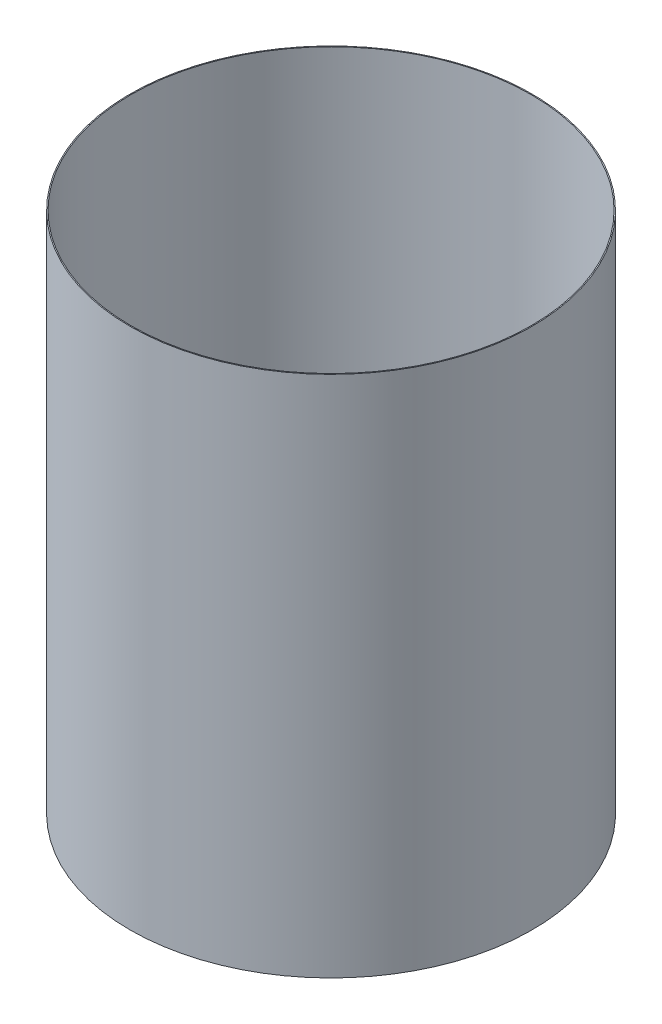
from build123d import *

# Parameters (mm, degrees)
SKETCH1_W = 0.254
SKETCH1_H = 133.35


with BuildPart() as part:
    # Sketch1 → Revolve-Thin1 (revolve)
    with BuildSketch(Plane.XY):
        with Locations((-51.181, -86.580914232)):
            Rectangle(SKETCH1_W, SKETCH1_H)
    revolve(axis=Axis((0, 55, 0), (0, -1, 0)))


solid = part.part
